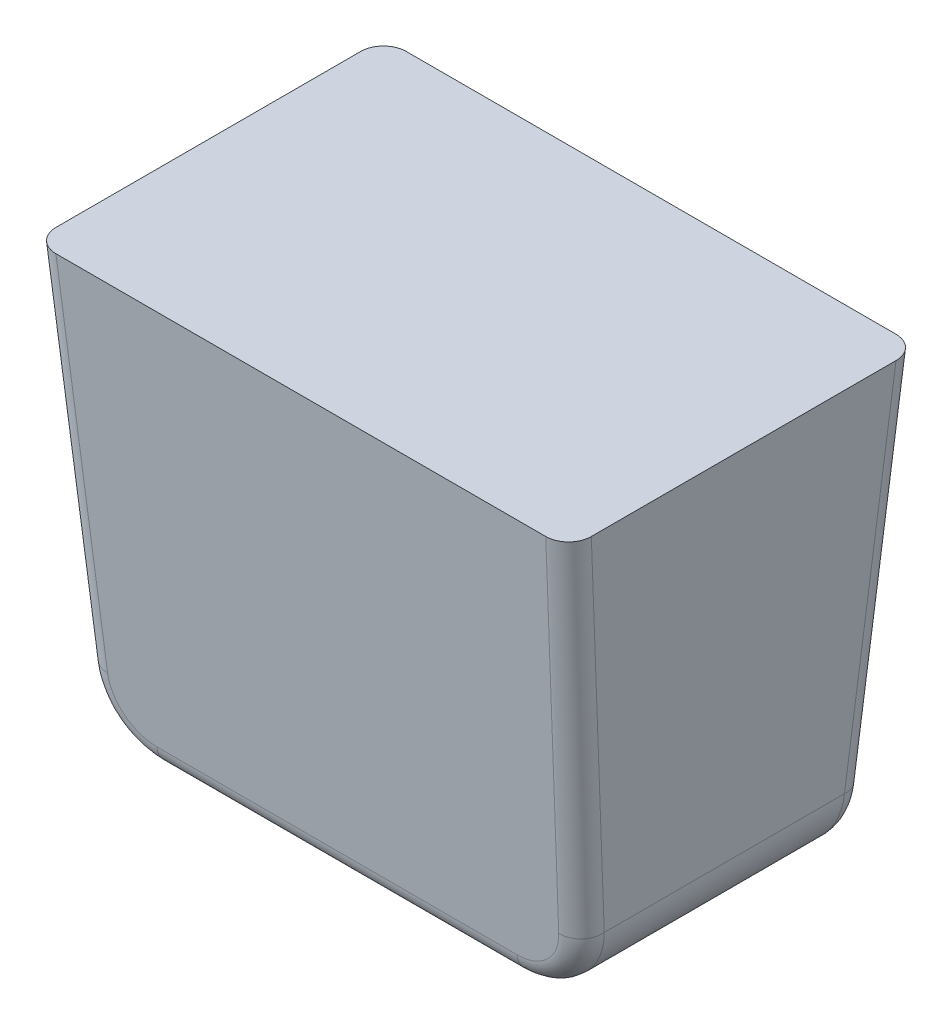
from build123d import *

# Parameters (mm, degrees)
SKETCH2_W           = 47.5
SKETCH2_H           = 31.66666
BOSS_EXTRUDE1_DEPTH = 43.5
DRAFT2_ANGLE        = -5
DRAFT3_ANGLE        = -5
DRAFT4_ANGLE        = -3
DRAFT5_ANGLE        = -3
FILLET1_R           = 6
FILLET2_R           = 2
SKETCH3_W           = 65.927175626
SKETCH3_H           = 41.406577606
CUT_EXTRUDE1_DEPTH  = 5.5


with BuildPart() as part:
    # Sketch2 → Boss-Extrude1 (new body)
    with BuildSketch(Plane(origin=(0, 0, 0), x_dir=(1, 0, 0), z_dir=(0, 1, 0))):
        Rectangle(SKETCH2_W, SKETCH2_H)
    extrude(amount=BOSS_EXTRUDE1_DEPTH)

    # Draft2
    draft2_faces = [part.faces().sort_by_distance(p)[0] for p in [
        (0, 21.75, 15.83333),
    ]]
    draft(draft2_faces, Plane.ZX.offset(43.5), DRAFT2_ANGLE)

    # Draft3
    draft3_faces = [part.faces().sort_by_distance(p)[0] for p in [
        (0, 21.75, -15.83333),
    ]]
    draft(draft3_faces, Plane.ZX.offset(43.5), DRAFT3_ANGLE)

    # Draft4
    draft4_faces = [part.faces().sort_by_distance(p)[0] for p in [
        (-23.75, 22.740338939, 0),
    ]]
    draft(draft4_faces, Plane.ZX.offset(43.5), DRAFT4_ANGLE)

    # Draft5
    draft5_faces = [part.faces().sort_by_distance(p)[0] for p in [
        (23.75, 22.740338939, 0),
    ]]
    draft(draft5_faces, Plane.ZX.offset(43.5), DRAFT5_ANGLE)

    # Fillet1
    fillet1_edges = [part.edges().sort_by_distance(p)[0] for p in [
        (21.470261601, 0, 0),
        (-21.470261601, 0, 0),
    ]]
    fillet(fillet1_edges, radius=FILLET1_R)

    # Fillet2
    fillet2_edges = [part.edges().sort_by_distance(p)[0] for p in [
        (23.75, 43.5, 0),
        (0, 43.5, -15.83333),
        (0, 0, 12.027573137),
        (19.910526358, 1.651481544, 12.17205905),
        (-19.910526358, 1.651481544, 12.17205905),
        (0, 0, -12.027573137),
        (19.910526358, 1.651481544, -12.17205905),
        (-19.910526358, 1.651481544, -12.17205905),
        (-23.75, 43.5, 0),
        (0, 43.5, 15.83333),
        (-22.759125705, 24.592992131, -14.17918115),
        (22.759125705, 24.592992131, -14.17918115),
        (22.759125705, 24.592992131, 14.17918115),
        (-22.759125705, 24.592992131, 14.17918115),
    ]]
    fillet(fillet2_edges, radius=FILLET2_R)

    # Sketch3 → Cut-Extrude1 (cut)
    with BuildSketch(Plane(origin=(0, 43.5, 0), x_dir=(1, 0, 0), z_dir=(0, 1, 0))):
        Rectangle(SKETCH3_W, SKETCH3_H)
    extrude(amount=-CUT_EXTRUDE1_DEPTH, mode=Mode.SUBTRACT)


solid = part.part
